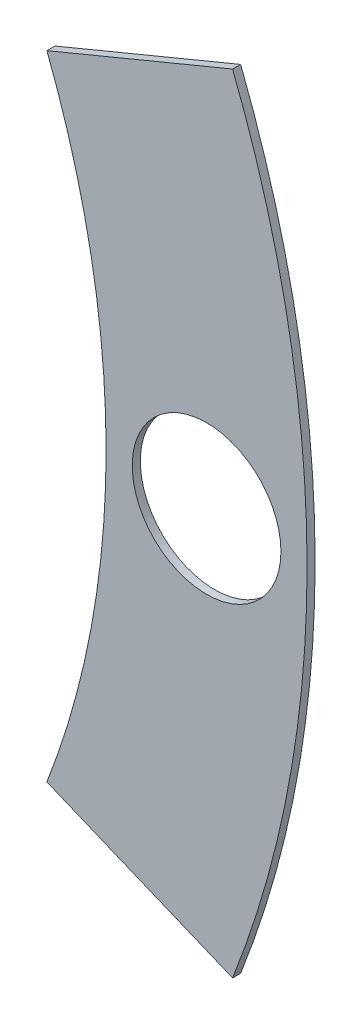
from build123d import *

# Parameters (mm, degrees)
SKETCH4_R           = 68.072
BOSS_EXTRUDE2_DEPTH = 0.508
SKETCH5_R           = 55.372
CUT_EXTRUDE5_DEPTH  = 1.508
SKETCH6_R           = 4.699
CUT_EXTRUDE6_DEPTH  = 1.508
SKETCH8_OUTSIDE_W   = 176.652
SKETCH8_OUTSIDE_H   = 176.652
CUT_EXTRUDE11_DEPTH = 1.508


with BuildPart() as part:
    # Sketch4 → Boss-Extrude2 (new body)
    with BuildSketch(Plane.XY):
        Circle(SKETCH4_R)
    extrude(amount=BOSS_EXTRUDE2_DEPTH)

    # Sketch5 → Cut-Extrude5 (cut, through all)
    with BuildSketch(Plane.XY.offset(0.508)):
        Circle(SKETCH5_R)
    extrude(amount=-CUT_EXTRUDE5_DEPTH, mode=Mode.SUBTRACT)

    # Sketch6 → Cut-Extrude6 (cut, through all)
    with BuildSketch(Plane.XY.offset(0.508)):
        with Locations((61.722, 0)):
            Circle(SKETCH6_R)
    extrude(amount=-CUT_EXTRUDE6_DEPTH, mode=Mode.SUBTRACT)

    # Sketch8 outside → Cut-Extrude11 (cut, through all)
    with BuildSketch(Plane.XY.offset(0.508)):
        Rectangle(SKETCH8_OUTSIDE_W, SKETCH8_OUTSIDE_H)
        with BuildLine():
            Line((51.629608078, -20.011045792), (63.365389329, -24.872165551))
            ThreePointArc((63.365389329, -24.872165551), (68.072, 0), (63.365389329, 24.872165551))
            Line((63.365389329, 24.872165551), (51.629608078, 20.011045792))
            ThreePointArc((51.629608078, 20.011045792), (55.372, 0), (51.629608078, -20.011045792))
        make_face(mode=Mode.SUBTRACT)
    extrude(amount=-CUT_EXTRUDE11_DEPTH, mode=Mode.SUBTRACT)


solid = part.part
